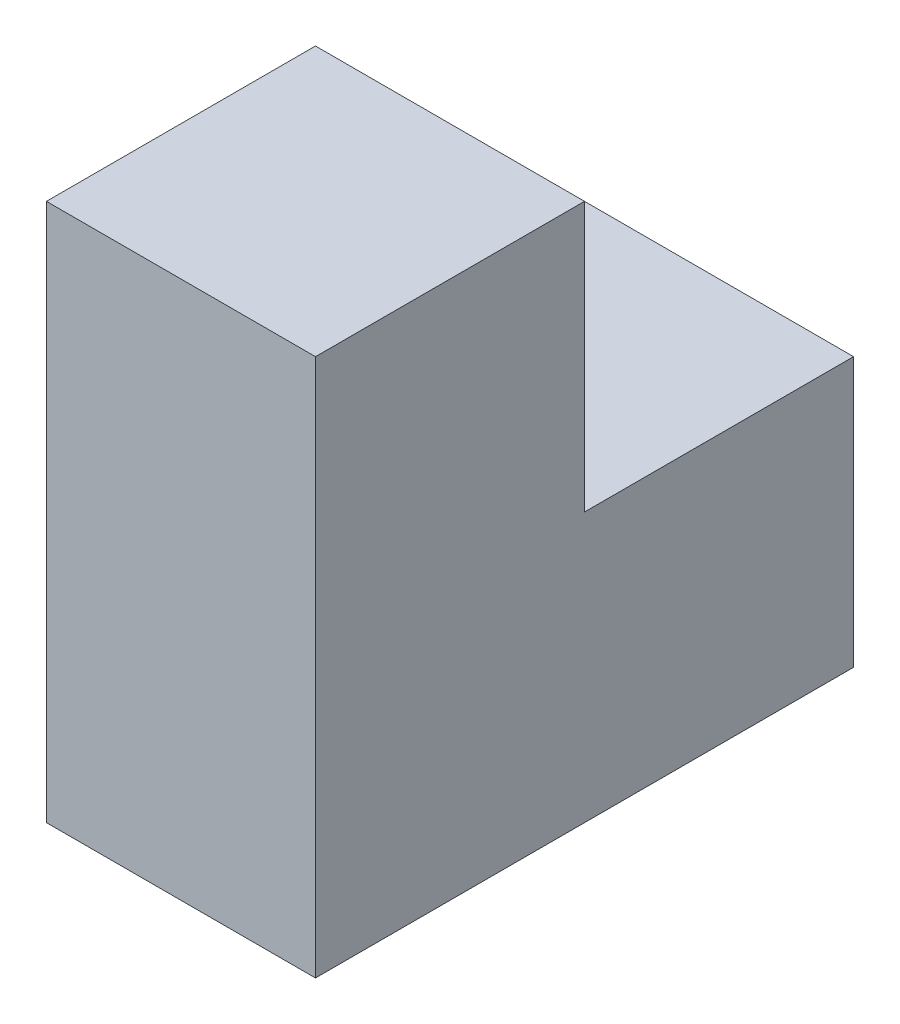
from build123d import *

# Parameters (mm, degrees)
BOSS_EXTRU_1_DEPTH = 30


with BuildPart() as part:
    # Esquisse1 → Boss.-Extru.1 (new body)
    with BuildSketch(Plane(origin=(0, 0, 0), x_dir=(0, 0, -1), z_dir=(1, 0, 0))):
        Polygon((0, 0), (60, 0), (60, 30), (30, 30), (30, 60), (0, 60), align=None)
    extrude(amount=BOSS_EXTRU_1_DEPTH)


solid = part.part
